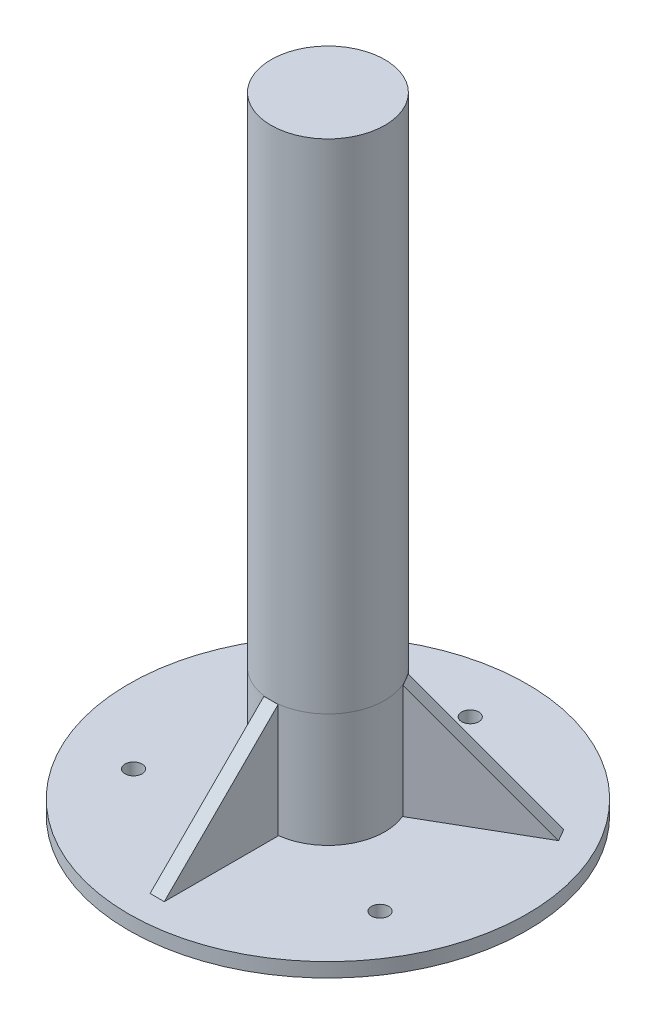
from build123d import *

# Parameters (mm, degrees)
SKETCH1_R           = 70
BOSS_EXTRUDE1_DEPTH = 5
SKETCH2_R           = 20
BOSS_EXTRUDE2_DEPTH = 40
SKETCH3_R           = 20
BOSS_EXTRUDE3_DEPTH = 175
BOSS_EXTRUDE4_DEPTH = 2.5
CIRPATTERN1_COUNT   = 3
SKETCH5_R           = 3
CUT_EXTRUDE1_DEPTH  = 237.696007571


with BuildPart() as part:
    # Sketch1 → Boss-Extrude1 (new body)
    with BuildSketch(Plane(origin=(0, 0, 0), x_dir=(1, 0, 0), z_dir=(0, 1, 0))):
        Circle(SKETCH1_R)
    extrude(amount=-BOSS_EXTRUDE1_DEPTH)


with BuildPart() as body_2:
    # Sketch2 → Boss-Extrude2 (new body)
    with BuildSketch(Plane(origin=(0, 0, 0), x_dir=(1, 0, 0), z_dir=(0, 1, 0))):
        Circle(SKETCH2_R)
    extrude(amount=BOSS_EXTRUDE2_DEPTH)


with BuildPart() as body_3:
    # Sketch3 → Boss-Extrude3 (new body)
    with BuildSketch(Plane(origin=(0, 40, 0), x_dir=(1, 0, 0), z_dir=(0, 1, 0))):
        Circle(SKETCH3_R)
    extrude(amount=BOSS_EXTRUDE3_DEPTH)


with BuildPart() as body_4:
    # Sketch4 → Boss-Extrude4 (new, symmetric)
    with BuildSketch(Plane(origin=(0, 0, 0), x_dir=(0, 0, -1), z_dir=(1, 0, 0))):
        Polygon((-60, 0), (-20, 0), (-20, 40), align=None)
    boss_extrude4 = extrude(amount=BOSS_EXTRUDE4_DEPTH, both=True)


with BuildPart() as part_1:
    add(part.part)

    # CirPattern1: Boss-Extrude4 ×3 about axis
    cirpattern1_axis = Axis((0, 40, 0), (0, -1, 0))
    for i in range(1, CIRPATTERN1_COUNT):
        add(boss_extrude4.rotate(cirpattern1_axis, i * 360 / CIRPATTERN1_COUNT))

    # Sketch5 → Cut-Extrude1 (cut, through all)
    with BuildSketch(Plane(origin=(0, 0, 0), x_dir=(1, 0, 0), z_dir=(0, 1, 0))):
        with Locations((0, 50)):
            Circle(SKETCH5_R)
        with Locations((43.301270189, -25)):
            Circle(SKETCH5_R)
        with Locations((-43.301270189, -25)):
            Circle(SKETCH5_R)
    extrude(amount=-CUT_EXTRUDE1_DEPTH, mode=Mode.SUBTRACT)


solid = Compound([body_2.part, body_3.part, body_4.part, part_1.part])
